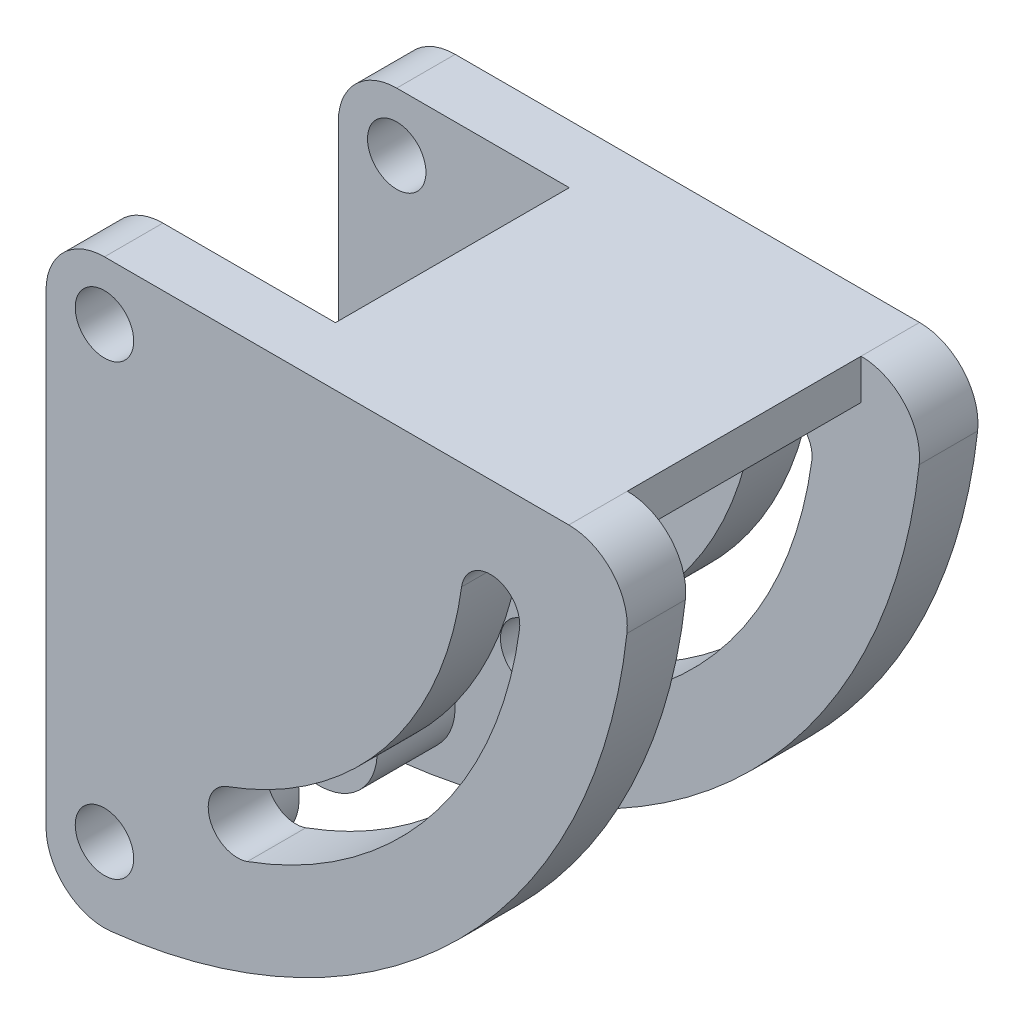
from build123d import *

# Parameters (mm, degrees)
SKETCH1_R           = 1.5
BOSS_EXTRUDE1_DEPTH = 3
LPATTERN1_COUNT     = 2
LPATTERN1_PITCH     = 15
FILLET2_R           = 3
FILLET3_R           = 3
SKETCH2_W           = 14.977515773
SKETCH2_H           = 2.058823846
BOSS_EXTRUDE2_DEPTH = 15
SKETCH3_R           = 3
SKETCH3_R_2         = 1.5
BOSS_EXTRUDE3_DEPTH = 4
LPATTERN2_COUNT     = 2
LPATTERN2_PITCH     = 8


with BuildPart() as part:
    # Sketch1 → Boss-Extrude1 (new body)
    with BuildSketch(Plane.XY):
        with BuildLine():
            Line((0, 0), (30, 0))
            ThreePointArc((30, 0), (21.213203436, -21.213203436), (0, -30))
            Line((0, -30), (0, 0))
        make_face()
        with Locations((3, -26)):
            Circle(SKETCH1_R, mode=Mode.SUBTRACT)
        with Locations((3, -3)):
            Circle(SKETCH1_R, mode=Mode.SUBTRACT)
        with BuildLine():
            ThreePointArc((21.329556778, -5.505463694), (17.394405246, -14.621148722), (9.313112731, -20.38949705))
            ThreePointArc((9.313112731, -20.38949705), (8.415027516, -22.311330275), (10.336860742, -23.20941549))
            ThreePointArc((10.336860742, -23.20941549), (19.728633123, -16.505659326), (24.301917337, -5.911755103))
            ThreePointArc((24.301917337, -5.911755103), (23.018882762, -4.222429119), (21.329556778, -5.505463694))
        make_face(mode=Mode.SUBTRACT)
    extrude(amount=BOSS_EXTRUDE1_DEPTH)


with BuildPart() as lpattern1_1:
    # LPattern1: pattern copy
    add(part.part.moved(Location(Vector(0, 0, 1) * (1 * LPATTERN1_PITCH))))

    # Fillet3
    fillet3_edges = [lpattern1_1.edges().sort_by_distance(p)[0] for p in [
        (0, 0, 16.5),
        (30, 0, 16.5),
        (0, -30, 16.5),
    ]]
    fillet(fillet3_edges, radius=FILLET3_R)


with BuildPart() as part_1:
    add(part.part)

    # Fillet2
    fillet2_edges = [part_1.edges().sort_by_distance(p)[0] for p in [
        (0, 0, 1.5),
        (30, 0, 1.5),
        (0, -30, 1.5),
    ]]
    fillet(fillet2_edges, radius=FILLET2_R)

    add(lpattern1_1.part)  # Boss-Extrude2 merges LPattern1_1
    # Sketch2 → Boss-Extrude2 (add)
    with BuildSketch(Plane.XY.offset(3)):
        with Locations((19.344057843, -1.029411923)):
            Rectangle(SKETCH2_W, SKETCH2_H)
    extrude(amount=BOSS_EXTRUDE2_DEPTH)

    # Sketch3 → Boss-Extrude3 (add)
    with BuildSketch(Plane(origin=(0, 0, 15), x_dir=(-1, 0, 0), z_dir=(0, 0, -1))):
        with Locations((-3, -26)):
            Circle(SKETCH3_R)
        with Locations((-3, -26)):
            Circle(SKETCH3_R_2, mode=Mode.SUBTRACT)
    boss_extrude3 = extrude(amount=BOSS_EXTRUDE3_DEPTH)

    # LPattern2: Boss-Extrude3 ×2
    with Locations(*[(0, 0, -i * LPATTERN2_PITCH) for i in range(1, LPATTERN2_COUNT)]):
        add(boss_extrude3)


solid = part_1.part
